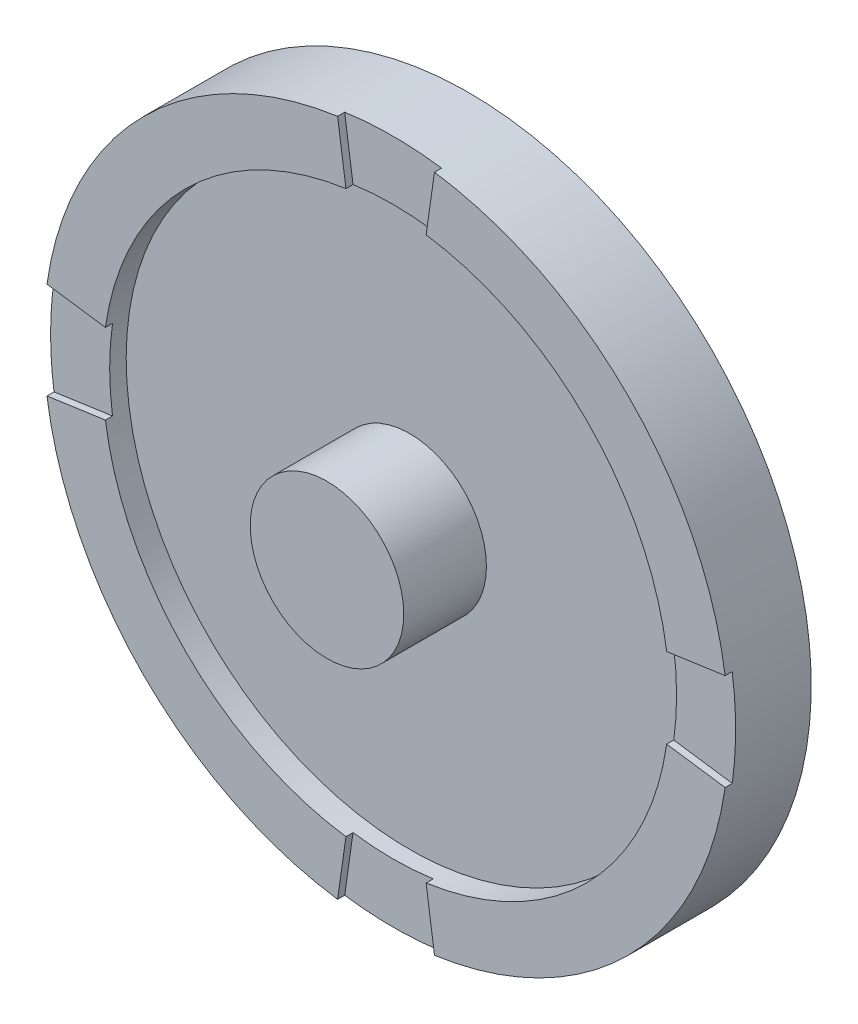
from build123d import *

# Parameters (mm, degrees)
SKETCH1_R          = 24
EXTRUDE1_DEPTH     = 5
SKETCH2_R          = 6.5
EXTRUDE2_DEPTH     = 7
SKETCH3_R          = 29
SKETCH3_R_2        = 24
EXTRUDE3_DEPTH     = 7
CUT_EXTRUDE1_DEPTH = 0.6


with BuildPart() as part:
    # Sketch1 → Extrude1 (new body)
    with BuildSketch(Plane.XY):
        Circle(SKETCH1_R)
    extrude(amount=EXTRUDE1_DEPTH)

    # Sketch2 → Extrude2 (add)
    with BuildSketch(Plane.XY.offset(5)):
        Circle(SKETCH2_R)
    extrude(amount=EXTRUDE2_DEPTH)

    # Sketch3 → Extrude3 (add)
    with BuildSketch(Plane(origin=(0, 0, 0), x_dir=(-1, 0, 0), z_dir=(0, 0, -1))):
        Circle(SKETCH3_R)
        Circle(SKETCH3_R_2, mode=Mode.SUBTRACT)
    extrude(amount=-EXTRUDE3_DEPTH)

    # Sketch4 → Cut-Extrude1 (cut)
    with BuildSketch(Plane.XY.offset(7)):
        with BuildLine():
            Line((3.39411255, 23.758787848), (4.101219331, 28.708535316))
            ThreePointArc((4.101219331, 28.708535316), (2.055781583, 28.927042056), (0, 29))
            ThreePointArc((0, 29), (-2.055781583, 28.927042056), (-4.101219331, 28.708535316))
            Line((-4.101219331, 28.708535316), (-3.39411255, 23.758787848))
            ThreePointArc((-3.39411255, 23.758787848), (-1.701336482, 23.939621012), (0, 24))
            ThreePointArc((0, 24), (1.701336482, 23.939621012), (3.39411255, 23.758787848))
        make_face()
        with BuildLine():
            Line((23.758787848, -3.39411255), (28.708535316, -4.101219331))
            ThreePointArc((28.708535316, -4.101219331), (28.927042056, -2.055781583), (29, 0))
            ThreePointArc((29, 0), (28.927042056, 2.055781583), (28.708535316, 4.101219331))
            Line((28.708535316, 4.101219331), (23.758787848, 3.39411255))
            ThreePointArc((23.758787848, 3.39411255), (23.939621012, 1.701336482), (24, 0))
            ThreePointArc((24, 0), (23.939621012, -1.701336482), (23.758787848, -3.39411255))
        make_face()
        with BuildLine():
            Line((3.39411255, -23.758787848), (4.101219331, -28.708535316))
            ThreePointArc((4.101219331, -28.708535316), (2.055781583, -28.927042056), (0, -29))
            ThreePointArc((0, -29), (-2.055781583, -28.927042056), (-4.101219331, -28.708535316))
            Line((-4.101219331, -28.708535316), (-3.39411255, -23.758787848))
            ThreePointArc((-3.39411255, -23.758787848), (-1.701336482, -23.939621012), (0, -24))
            ThreePointArc((0, -24), (1.701336482, -23.939621012), (3.39411255, -23.758787848))
        make_face()
        with BuildLine():
            Line((-23.758787848, -3.39411255), (-28.708535316, -4.101219331))
            ThreePointArc((-28.708535316, -4.101219331), (-28.927042056, -2.055781583), (-29, 0))
            ThreePointArc((-29, 0), (-28.927042056, 2.055781583), (-28.708535316, 4.101219331))
            Line((-28.708535316, 4.101219331), (-23.758787848, 3.39411255))
            ThreePointArc((-23.758787848, 3.39411255), (-23.939621012, 1.701336482), (-24, 0))
            ThreePointArc((-24, 0), (-23.939621012, -1.701336482), (-23.758787848, -3.39411255))
        make_face()
    extrude(amount=-CUT_EXTRUDE1_DEPTH, mode=Mode.SUBTRACT)


solid = part.part
